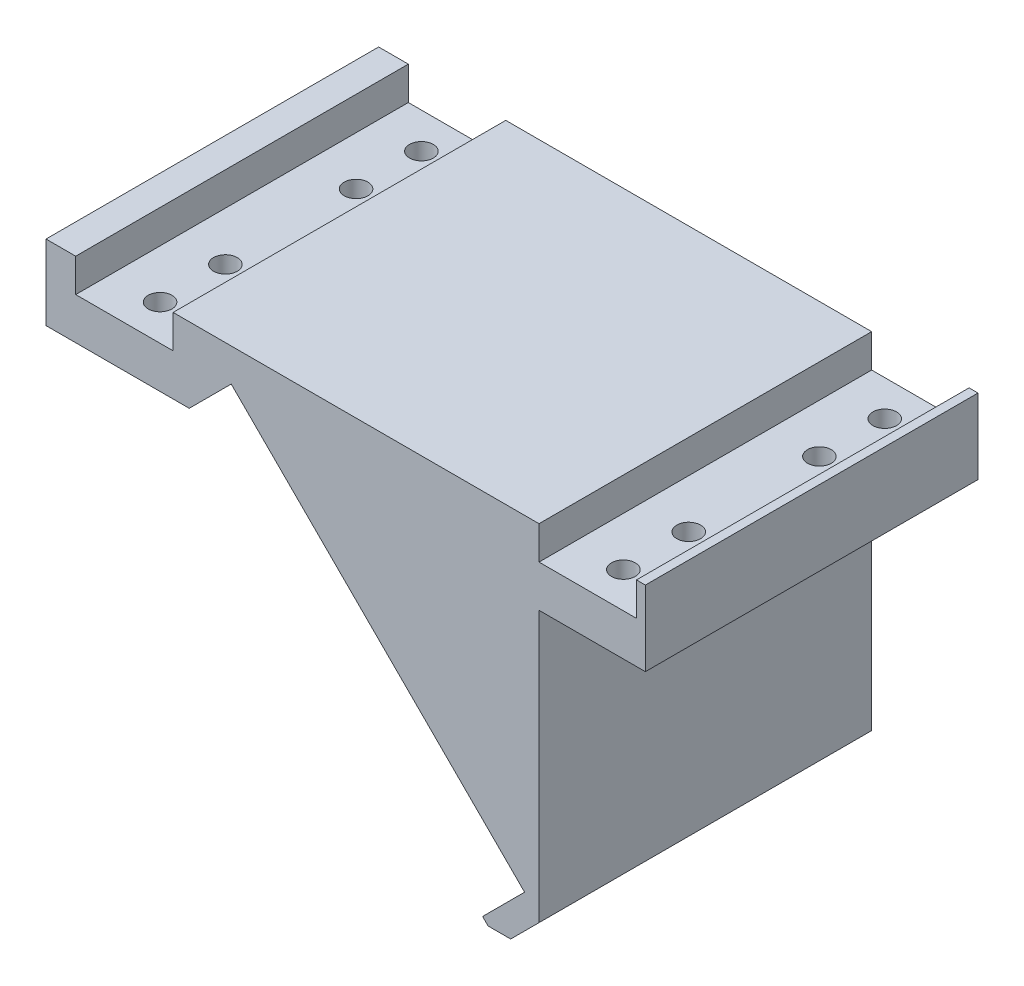
from build123d import *

# Parameters (mm, degrees)
BOSS_EXTRUDE1_DEPTH          = 25
BOSS_EXTRUDE2_DEPTH          = 3
M4X0_7_TAPPED_HOLE1_D        = 3.3
M4X0_7_TAPPED_HOLE1_DEPTH    = 14
M4X0_7_TAPPED_HOLE1_TIP      = 0.991420021
F_2_0_2_DIAMETER_HOLE1_D     = 2
F_2_0_2_DIAMETER_HOLE1_DEPTH = 3.512823811
F_2_0_2_DIAMETER_HOLE2_D     = 2
F_2_0_2_DIAMETER_HOLE2_DEPTH = 3.512823811
M3X0_5_TAPPED_HOLE1_D        = 2.5
M3X0_5_TAPPED_HOLE1_DEPTH    = 2


with BuildPart() as part:
    # Sketch1 → Boss-Extrude1 (new body)
    with BuildSketch(Plane.XY):
        Polygon((13.697937079, 25.419129705), (16.197937079, 25.419129705), (16.197937079, 22.619129705), (24.397937079, 22.619129705), (24.397937079, 25.419129705), (55.197937079, 25.419129705), (55.197937079, 22.619129705), (63.397937079, 22.619129705), (63.397937079, 25.419129705), (64.147937079, 25.419129705), (64.147937079, 19.106305894), (55.197937079, 19.106305894), (55.197937079, -3.66605846), (52.811898109, -6.05209743), (50.912403173, -6.05209743), (50.447937079, -5.587631336), (53.983470985, -2.05209743), (29.289533755, 22.6418398), (25.753999849, 19.106305894), (13.697937079, 19.106305894), align=None)
    extrude(amount=BOSS_EXTRUDE1_DEPTH)

    # Sketch2 → Boss-Extrude2 (add)
    with BuildSketch(Plane(origin=(0, 0, 0), x_dir=(-1, 0, 0), z_dir=(0, 0, -1))):
        Polygon((-64.147937079, 25.419129705), (-63.397937079, 25.419129705), (-63.397937079, 22.619129705), (-55.197937079, 22.619129705), (-55.197937079, 25.419129705), (-24.397937079, 25.419129705), (-24.397937079, 22.619129705), (-16.197937079, 22.619129705), (-16.197937079, 25.419129705), (-13.697937079, 25.419129705), (-13.697937079, 19.106305894), (-25.753999849, 19.106305894), (-29.289533755, 22.6418398), (-32.825067661, 19.106305894), (-29.289533755, 15.570771988), (-46.912403173, -2.05209743), (-50.447937079, 1.483436476), (-53.983470985, -2.05209743), (-50.447937079, -5.587631336), (-50.912403173, -6.05209743), (-52.811898109, -6.05209743), (-55.197937079, -3.66605846), (-55.197937079, 19.106305894), (-64.147937079, 19.106305894), align=None)
    extrude(amount=BOSS_EXTRUDE2_DEPTH)

    # M4x0.7 Tapped Hole1
    with Locations(Plane(origin=(0, 0, -3), x_dir=(-1, 0, 0), z_dir=(0, 0, -1))):
        with Locations((-46.197937079, 15.419129705)):
            Hole(M4X0_7_TAPPED_HOLE1_D / 2, depth=M4X0_7_TAPPED_HOLE1_DEPTH)
            with Locations((0, 0, -(M4X0_7_TAPPED_HOLE1_DEPTH + M4X0_7_TAPPED_HOLE1_TIP / 2))):  # 118° drill point
                Cone(0, M4X0_7_TAPPED_HOLE1_D / 2, M4X0_7_TAPPED_HOLE1_TIP, mode=Mode.SUBTRACT)

    # Ø2.0 (2) Diameter Hole1
    with Locations(Plane(origin=(0, 19.106305894, 0), x_dir=(-1, 0, 0), z_dir=(0, -1, 0))):
        with Locations((-59.297937079, -22), (-59.297937079, -16.5), (-59.297937079, -5.5), (-59.297937079, 0)):
            Hole(F_2_0_2_DIAMETER_HOLE1_D / 2, depth=F_2_0_2_DIAMETER_HOLE1_DEPTH)

    # Ø2.0 (2) Diameter Hole2
    with Locations(Plane(origin=(0, 19.106305894, 0), x_dir=(-1, 0, 0), z_dir=(0, -1, 0))):
        with Locations((-20.297937079, -22), (-20.297937079, -16.5), (-20.297937079, -5.5), (-20.297937079, 0)):
            Hole(F_2_0_2_DIAMETER_HOLE2_D / 2, depth=F_2_0_2_DIAMETER_HOLE2_DEPTH)

    # M3x0.5 Tapped Hole1
    with Locations(Plane(origin=(29.43199777, -29.43199777, 0), x_dir=(0, 0, -1), z_dir=(0.707106781, -0.707106781, 0))):
        with Locations((-11, 34.764172148)):
            Hole(M3X0_5_TAPPED_HOLE1_D / 2, depth=M3X0_5_TAPPED_HOLE1_DEPTH)


solid = part.part
